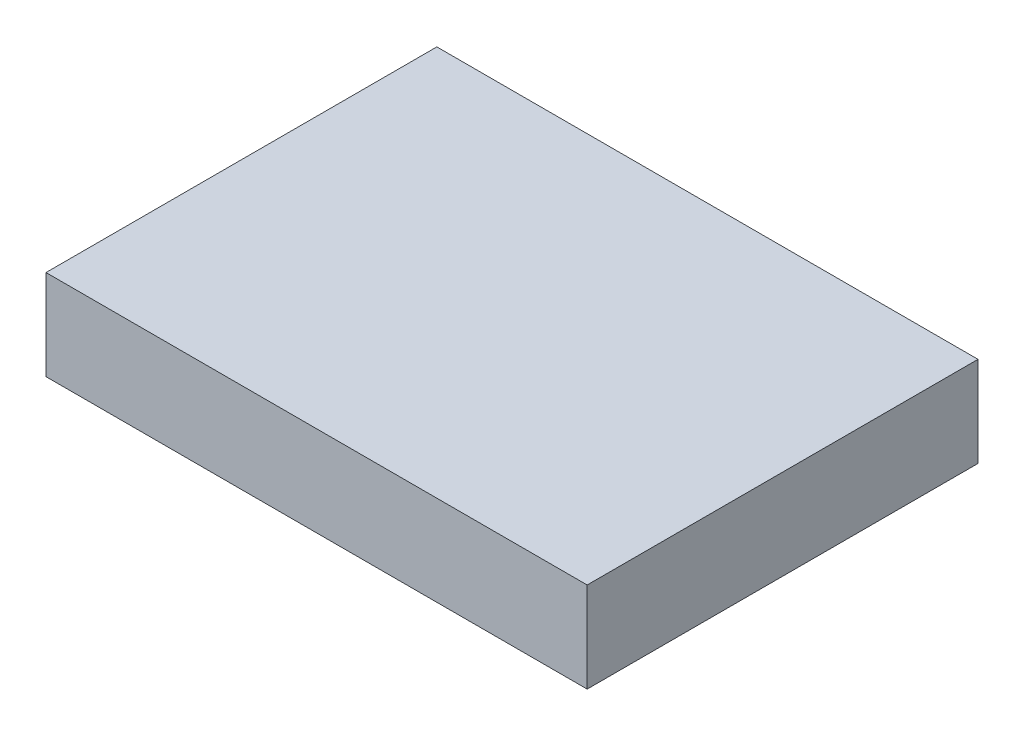
from build123d import *

# Parameters (mm, degrees)
SKETCH1_W      = 180
SKETCH1_H      = 130
EXTRUDE1_DEPTH = 30


with BuildPart() as part:
    # Sketch1 → Extrude1 (new body)
    with BuildSketch(Plane(origin=(0, 0, 0), x_dir=(1, 0, 0), z_dir=(0, 1, 0))):
        with Locations((90, 65)):
            Rectangle(SKETCH1_W, SKETCH1_H)
    extrude(amount=EXTRUDE1_DEPTH)


solid = part.part
